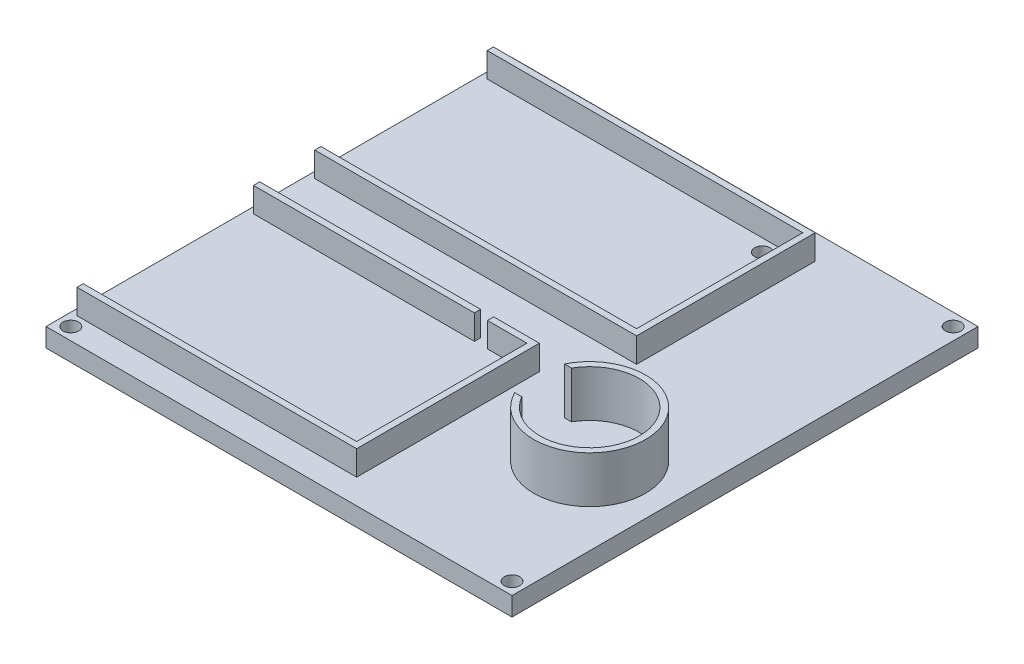
from build123d import *

# Parameters (mm, degrees)
SKETCH1_W           = 150
SKETCH1_H           = 150
BOSS_EXTRUDE1_DEPTH = 6
SKETCH2_W           = 71.08
SKETCH2_H           = 2
SKETCH2_R           = 18
SKETCH2_R_2         = 16
BOSS_EXTRUDE2_DEPTH = 7.94
SKETCH3_R           = 18
SKETCH3_R_2         = 16
BOSS_EXTRUDE3_DEPTH = 7.06
SKETCH5_R           = 2.5
CUT_EXTRUDE1_DEPTH  = 7
CUT_EXTRUDE2_DEPTH  = 15


with BuildPart() as part:
    # Sketch1 → Boss-Extrude1 (new body)
    with BuildSketch(Plane(origin=(0, 0, 0), x_dir=(1, 0, 0), z_dir=(0, 1, 0))):
        Rectangle(SKETCH1_W, SKETCH1_H)
    extrude(amount=BOSS_EXTRUDE1_DEPTH)

    # Sketch2 → Boss-Extrude2 (add)
    with BuildSketch(Plane(origin=(0, 6, 0), x_dir=(1, 0, 0), z_dir=(0, 1, 0))):
        Polygon((30.6, 67), (-73, 67), (-73, 65), (28.6, 65), (28.6, 11.5), (-73, 11.5), (-73, 9.5), (30.6, 9.5), align=None)
        with Locations((-37.46, -9.2)):
            Rectangle(SKETCH2_W, SKETCH2_H)
        Polygon((-73, -65), (-73, -67), (17, -67), (17, -8.2), (2.3, -8.2), (2.3, -10.2), (15, -10.2), (15, -65), align=None)
        with Locations((50, -25)):
            Circle(SKETCH2_R)
        with Locations((50, -25)):
            Circle(SKETCH2_R_2, mode=Mode.SUBTRACT)
    extrude(amount=BOSS_EXTRUDE2_DEPTH)

    # Sketch3 → Boss-Extrude3 (add)
    with BuildSketch(Plane(origin=(0, 13.94, 0), x_dir=(1, 0, 0), z_dir=(0, 1, 0))):
        with Locations((50, -25)):
            Circle(SKETCH3_R)
        with Locations((50, -25)):
            Circle(SKETCH3_R_2, mode=Mode.SUBTRACT)
    extrude(amount=BOSS_EXTRUDE3_DEPTH)

    # Sketch5 → Cut-Extrude1 (cut, through all)
    with BuildSketch(Plane(origin=(0, 6, 0), x_dir=(1, 0, 0), z_dir=(0, 1, 0))):
        with Locations((-71, 71)):
            Circle(SKETCH5_R)
        with Locations((19.6, 61)):
            Circle(SKETCH5_R)
        with Locations((24.6, 15.5)):
            Circle(SKETCH5_R)
        with Locations((71, 71)):
            Circle(SKETCH5_R)
        with Locations((71, -71)):
            Circle(SKETCH5_R)
        with Locations((-71, -71)):
            Circle(SKETCH5_R)
    extrude(amount=-CUT_EXTRUDE1_DEPTH, mode=Mode.SUBTRACT)

    # Sketch6 → Cut-Extrude2 (cut)
    with BuildSketch(Plane(origin=(0, 21, 0), x_dir=(1, 0, 0), z_dir=(0, 1, 0))):
        with BuildLine():
            Line((33.875484503, -33), (33.875484503, -17))
            ThreePointArc((33.875484503, -17), (32, -25), (33.875484503, -33))
        make_face()
        with BuildLine():
            ThreePointArc((36.143593539, -33), (34, -25), (36.143593539, -17))
            Line((36.143593539, -17), (33.875484503, -17))
            Line((33.875484503, -17), (33.875484503, -33))
            Line((33.875484503, -33), (36.143593539, -33))
        make_face()
    extrude(amount=-CUT_EXTRUDE2_DEPTH, mode=Mode.SUBTRACT)


solid = part.part
